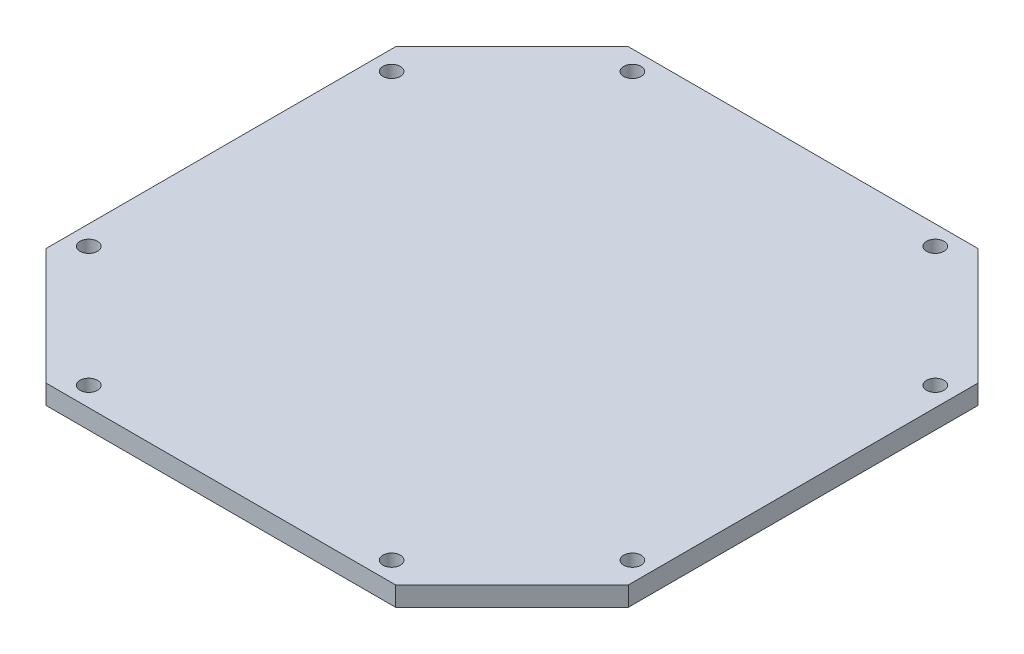
from build123d import *

# Parameters (mm, degrees)
SKETCH1_W           = 60
SKETCH1_H           = 180
SKETCH1_W_2         = 180
SKETCH1_H_2         = 60
BOSS_EXTRUDE1_DEPTH = 10
SKETCH2_R           = 4.5
CUT_EXTRUDE1_DEPTH  = 11


with BuildPart() as part:
    # Sketch1 → Boss-Extrude1 (new body)
    with BuildSketch(Plane(origin=(0, 0, 0), x_dir=(1, 0, 0), z_dir=(0, 1, 0))):
        with Locations((-120, 0)):
            Rectangle(SKETCH1_W, SKETCH1_H)
        Polygon((-90, -90), (-150, -90), (-90, -150), align=None)
        Polygon((-90, 90), (-90, 150), (-150, 90), align=None)
        with Locations((0, 120)):
            Rectangle(SKETCH1_W_2, SKETCH1_H_2)
        Rectangle(SKETCH1_W_2, SKETCH1_H)
        with Locations((0, -120)):
            Rectangle(SKETCH1_W_2, SKETCH1_H_2)
        Polygon((150, -90), (90, -90), (90, -150), align=None)
        with Locations((120, 0)):
            Rectangle(SKETCH1_W, SKETCH1_H)
        Polygon((150, 90), (90, 150), (90, 90), align=None)
    extrude(amount=BOSS_EXTRUDE1_DEPTH)

    # Sketch2 → Cut-Extrude1 (cut, through all)
    with BuildSketch(Plane(origin=(0, 10, 0), x_dir=(1, 0, 0), z_dir=(0, 1, 0))):
        with Locations((-78, 140)):
            Circle(SKETCH2_R)
        with Locations((-140, 78)):
            Circle(SKETCH2_R)
        with Locations((-140, -78)):
            Circle(SKETCH2_R)
        with Locations((-78, -140)):
            Circle(SKETCH2_R)
        with Locations((78, -140)):
            Circle(SKETCH2_R)
        with Locations((140, -78)):
            Circle(SKETCH2_R)
        with Locations((140, 78)):
            Circle(SKETCH2_R)
        with Locations((78, 140)):
            Circle(SKETCH2_R)
    extrude(amount=-CUT_EXTRUDE1_DEPTH, mode=Mode.SUBTRACT)


solid = part.part
